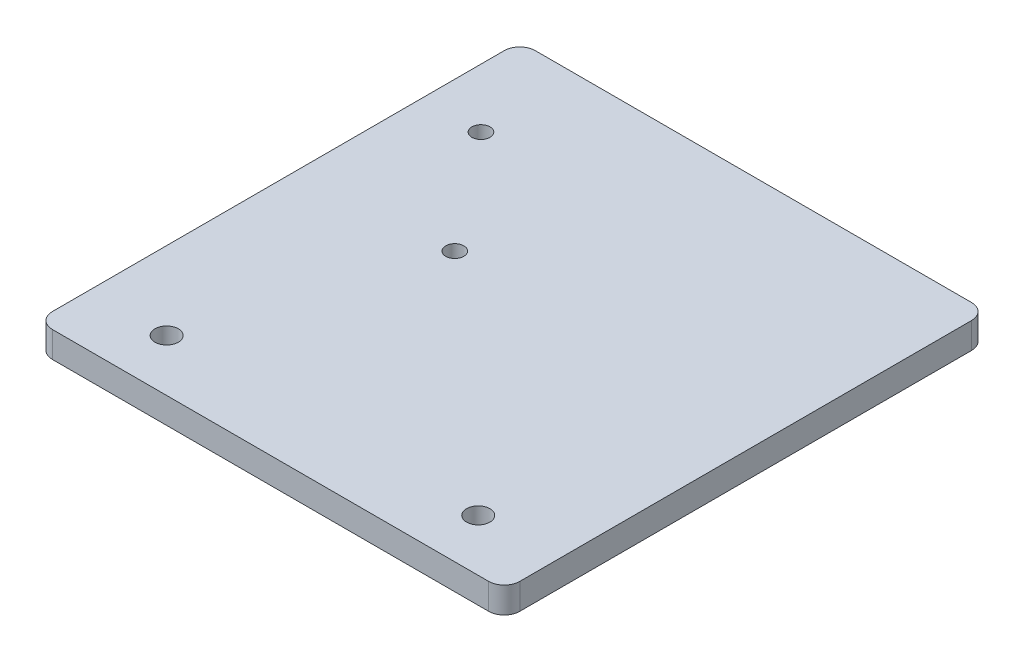
from build123d import *

# Parameters (mm, degrees)
SKETCH1_W           = 90
SKETCH1_H           = 93
SKETCH1_R           = 2.25
SKETCH1_R_2         = 1.75
BOSS_EXTRUDE1_DEPTH = 5
FILLET1_R           = 3


with BuildPart() as part:
    # Sketch1 → Boss-Extrude1 (new body)
    with BuildSketch(Plane(origin=(0, 0, 0), x_dir=(1, 0, 0), z_dir=(0, 1, 0))):
        Rectangle(SKETCH1_W, SKETCH1_H)
        with Locations((-30, -36.5)):
            Circle(SKETCH1_R, mode=Mode.SUBTRACT)
        with Locations((30, -36.5)):
            Circle(SKETCH1_R, mode=Mode.SUBTRACT)
        with Locations((-33.66, 27.68)):
            Circle(SKETCH1_R_2, mode=Mode.SUBTRACT)
        with Locations((-16.34, 5.32)):
            Circle(SKETCH1_R_2, mode=Mode.SUBTRACT)
    extrude(amount=BOSS_EXTRUDE1_DEPTH)

    # Fillet1
    fillet1_edges = [part.edges().sort_by_distance(p)[0] for p in [
        (45, 2.5, 46.5),
        (-45, 2.5, 46.5),
        (-45, 2.5, -46.5),
        (45, 2.5, -46.5),
    ]]
    fillet(fillet1_edges, radius=FILLET1_R)


solid = part.part
